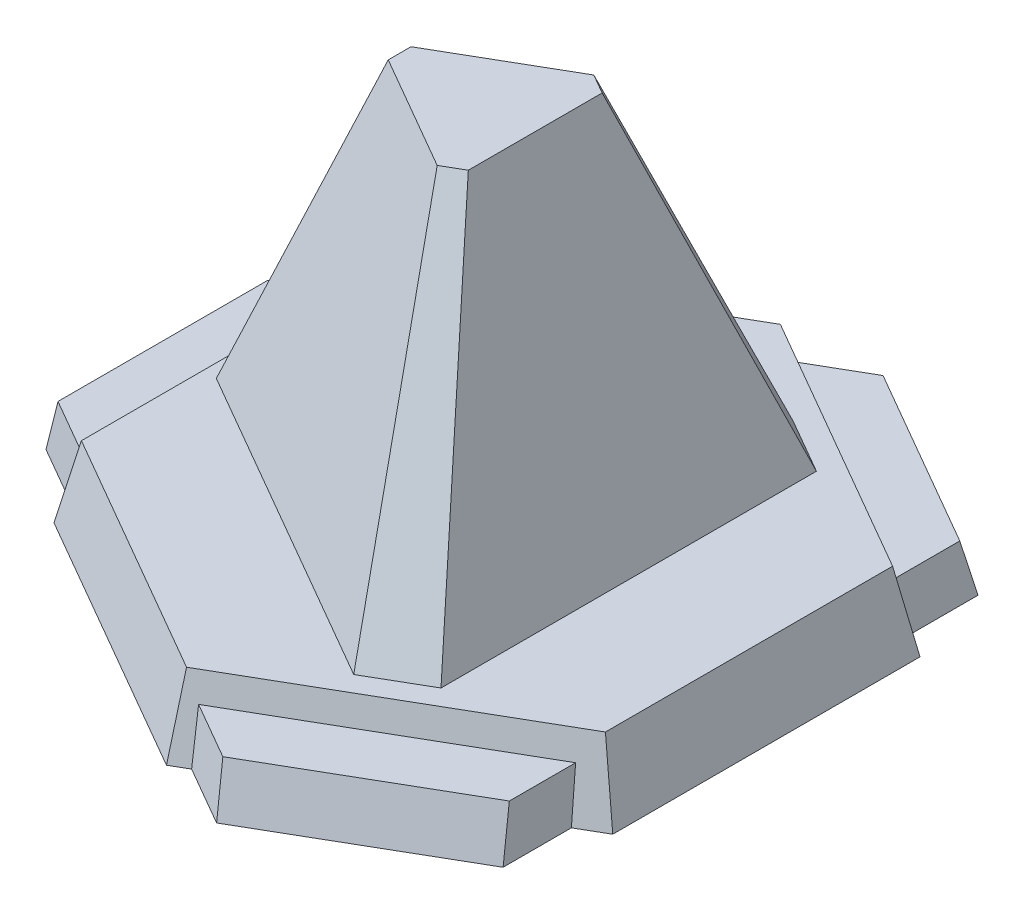
from build123d import *

# Parameters (mm, degrees)
PATTERN_CIRCULAR_1_COUNT = 3


with BuildPart() as part:
    # 草图4 → 放样5 section 0
    with BuildSketch(Plane(origin=(0, 200, 0), x_dir=(1, 0, 0), z_dir=(0, 1, 0))):
        Polygon((0, 793.295), (-664.472424785, 409.655), (-664.472424785, -409.655), (0, -793.295), (709.5403868, -383.635), (709.5403868, 383.635), align=None)
    # 草图1 → 放样5 section 1
    with BuildSketch(Plane(origin=(0, 0, 0), x_dir=(1, 0, 0), z_dir=(0, 1, 0))):
        Polygon((-710.882424785, -436.449593178), (-1.2807e-05, -846.88487741), (755.9503868, -410.429607966), (755.9503868, 410.429607966), (-1.2807e-05, 846.88487741), (-710.882424785, 436.449593178), align=None)
    loft()

    # 草图8 → 放样8 section 0
    with BuildSketch(Plane(origin=(0, 130.08, 0), x_dir=(1, 0, 0), z_dir=(0, 1, 0))):
        Polygon((-676.032424785, 384.41), (-676.032424785, -384.41), (-856.59006122, -280.165), (-856.59006122, 280.165), align=None)
    # 草图7 → 放样8 section 1
    with BuildSketch(Plane(origin=(0, 0, 0), x_dir=(1, 0, 0), z_dir=(0, 1, 0))):
        Polygon((-710.882424785, 387.274170973), (-891.44006122, 283.029170973), (-891.44006122, -277.300829027), (-710.882424785, -381.545829027), align=None)
    loft_8 = loft()

    # 阵列(圆周)1: 放样8 ×3 about axis
    pattern_circular_1_axis = Axis((0, 0, 0), (0, 1, 0))
    for i in range(1, PATTERN_CIRCULAR_1_COUNT):
        add(loft_8.rotate(pattern_circular_1_axis, i * 360 / PATTERN_CIRCULAR_1_COUNT))

    # 草图11 → 放样9 section 0
    with BuildSketch(Plane(origin=(0, 1111.8, 0), x_dir=(1, 0, 0), z_dir=(0, 1, 0))):
        Polygon((-223.984859664, 30.416313823), (-223.984859664, -30.413899524), (85.653863205, -209.183899524), (138.334158952, -178.768421621), (138.334158952, 178.771578379), (85.653648875, 209.186685053), align=None)
    # 草图10 → 放样9 section 1
    with BuildSketch(Plane(origin=(0, 200, 0), x_dir=(1, 0, 0), z_dir=(0, 1, 0))):
        Polygon((240.301512133, 586.87442815), (388.097407543, 501.54442815), (388.097407543, -501.53557185), (240.30211344, -586.866613336), (-628.39064859, -85.32661334), (-628.39064859, 85.33338666), align=None)
    loft()


solid = part.part
